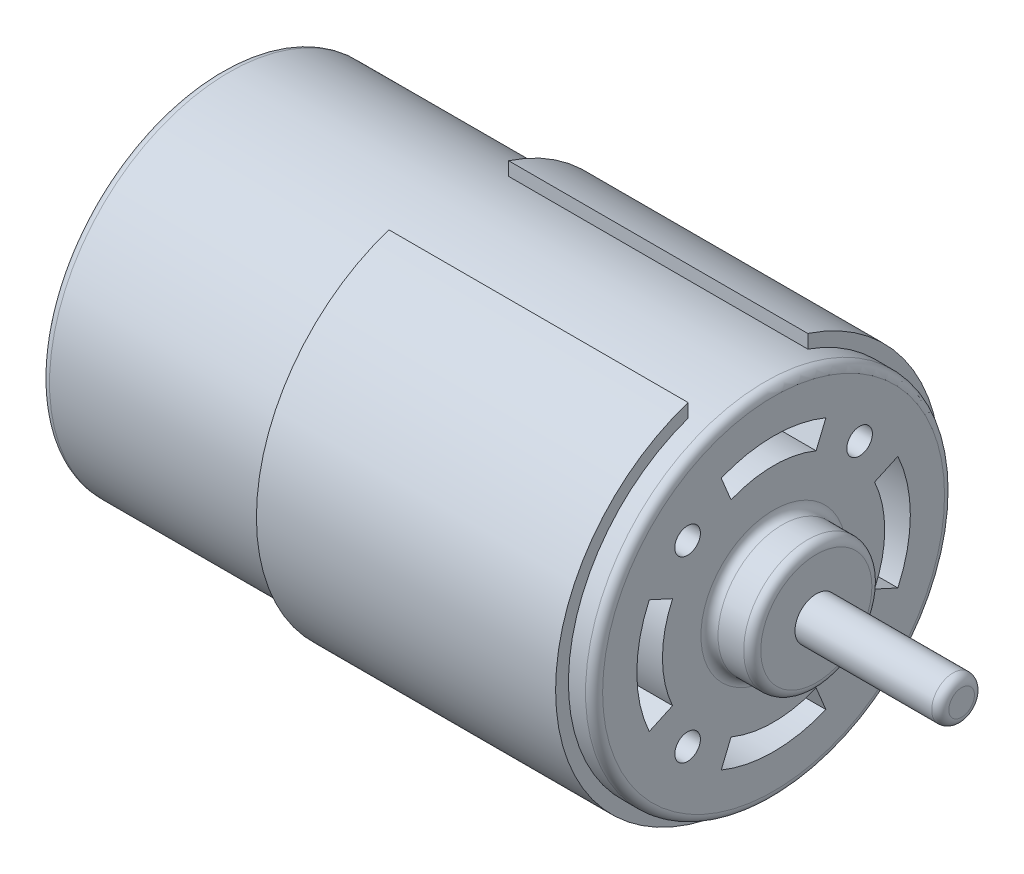
from build123d import *

# Parameters (mm, degrees)
SKETCH1_R               = 21
BOSS_EXTRUDE1_DEPTH     = 26.7
SKETCH2_R               = 22.5
BOSS_EXTRUDE2_DEPTH     = 35
SKETCH3_R               = 21
BOSS_EXTRUDE3_DEPTH     = 3
SKETCH4_R               = 7.5
BOSS_EXTRUDE4_DEPTH     = 5
SKETCH5_R               = 2.5
BOSS_EXTRUDE5_DEPTH     = 17
CUT_EXTRUDE1_REACH      = 105.824
CUT_EXTRUDE1_END_RADIUS = 21
SKETCH6_W               = 35
SKETCH6_H               = 14
FILLET1_R               = 1
SKETCH7_R               = 7.5
BOSS_EXTRUDE6_DEPTH     = 5
SKETCH8_R               = 2.5
BOSS_EXTRUDE7_DEPTH     = 5
CHAMFER1_SIZE           = 2
FILLET2_R               = 1
SKETCH9_R               = 1.5
CUT_EXTRUDE2_DEPTH      = 10


with BuildPart() as part:
    # Sketch1 → Boss-Extrude1 (new body)
    with BuildSketch(Plane(origin=(0, 0, 0), x_dir=(0, 0, -1), z_dir=(1, 0, 0))):
        with Locations(Location((0, 0, 0), (0, 0, 180))):
            Circle(SKETCH1_R)
    extrude(amount=BOSS_EXTRUDE1_DEPTH)

    # Sketch2 → Boss-Extrude2 (add)
    with BuildSketch(Plane(origin=(26.7, 0, 0), x_dir=(0, 0, -1), z_dir=(1, 0, 0))):
        Circle(SKETCH2_R)
    extrude(amount=BOSS_EXTRUDE2_DEPTH)

    # Sketch3 → Boss-Extrude3 (add)
    with BuildSketch(Plane(origin=(61.7, 0, 0), x_dir=(0, 0, -1), z_dir=(1, 0, 0))):
        with Locations(Location((0, 0, 0), (0, 0, 180))):
            Circle(SKETCH3_R)
    extrude(amount=BOSS_EXTRUDE3_DEPTH)

    # Sketch4 → Boss-Extrude4 (add)
    with BuildSketch(Plane(origin=(64.7, 0, 0), x_dir=(0, 0, -1), z_dir=(1, 0, 0))):
        Circle(SKETCH4_R)
    extrude(amount=BOSS_EXTRUDE4_DEPTH)

    # Sketch5 → Boss-Extrude5 (add)
    with BuildSketch(Plane(origin=(69.7, 0, 0), x_dir=(0, 0, -1), z_dir=(1, 0, 0))):
        Circle(SKETCH5_R)
    extrude(amount=BOSS_EXTRUDE5_DEPTH)

    # Cut-Extrude1: up to this cylinder (the profile starts outside it)
    cut_extrude1_end = Plane(origin=(44.2, 0, 0), z_dir=(-1, 0, 0)) * Cylinder(CUT_EXTRUDE1_END_RADIUS, 254.648, mode=Mode.PRIVATE)
    # Sketch6 → Cut-Extrude1 (cut, up to the surface)
    with BuildSketch(Plane(origin=(0, 30, 0), x_dir=(1, 0, 0), z_dir=(0, 1, 0)), mode=Mode.PRIVATE) as cut_extrude1_sk1:
        with Locations((44.2, 0)):
            Rectangle(SKETCH6_W, SKETCH6_H)
    cut_extrude1_tool1 = extrude(cut_extrude1_sk1.sketch, amount=-CUT_EXTRUDE1_REACH, mode=Mode.PRIVATE) - cut_extrude1_end
    add(cut_extrude1_tool1.solids().sort_by_distance((44.2, 30, 0))[0], mode=Mode.SUBTRACT)

    # Fillet1
    fillet1_edges = [part.edges().sort_by_distance(p)[0] for p in [
        (64.7, 0, -21),
        (64.7, 0, 7.5),
        (69.7, 0, 7.5),
        (0, 0, -21),
    ]]
    fillet(fillet1_edges, radius=FILLET1_R)

    # Sketch7 → Boss-Extrude6 (add)
    with BuildSketch(Plane.ZY):
        with Locations(Location((0, 0, 0), (0, 0, 180))):
            Circle(SKETCH7_R)
    extrude(amount=BOSS_EXTRUDE6_DEPTH)

    # Sketch8 → Boss-Extrude7 (add)
    with BuildSketch(Plane.ZY.offset(5)):
        with Locations(Location((0, 0, 0), (0, 0, 180))):
            Circle(SKETCH8_R)
    extrude(amount=BOSS_EXTRUDE7_DEPTH)

    # Chamfer1
    chamfer1_edges = [part.edges().sort_by_distance(p)[0] for p in [
        (-5, 0, 7.5),
    ]]
    chamfer(chamfer1_edges, length=CHAMFER1_SIZE)

    # Fillet2
    fillet2_edges = [part.edges().sort_by_distance(p)[0] for p in [
        (86.7, 0, 2.5),
        (0, 0, 7.5),
        (-10, 0, 2.5),
        (-3, 0, 7.5),
    ]]
    fillet(fillet2_edges, radius=FILLET2_R)

    # Sketch9 → Cut-Extrude2 (cut)
    with BuildSketch(Plane(origin=(64.7, 0, 0), x_dir=(0, 0, -1), z_dir=(1, 0, 0))):
        with Locations((-10.059860621, 10.442662701)):
            Circle(SKETCH9_R)
        with BuildLine():
            ThreePointArc((-4.974884621, 12.010433923), (-2.536174186, 12.750208645), (0, 13))
            ThreePointArc((0, 13), (2.536174186, 12.750208645), (4.974884621, 12.010433923))
            Line((4.974884621, 12.010433923), (5.548909769, 13.396253221))
            Line((5.548909769, 13.396253221), (6.122934918, 14.78207252))
            ThreePointArc((6.122934918, 14.78207252), (3.121445152, 15.692564486), (0, 16))
            ThreePointArc((0, 16), (-3.121445152, 15.692564486), (-6.122934918, 14.78207252))
            Line((-6.122934918, 14.78207252), (-5.548909769, 13.396253221))
            Line((-5.548909769, 13.396253221), (-4.974884621, 12.010433923))
        make_face()
        with Locations((10.059860621, 10.442662701)):
            Circle(SKETCH9_R)
        with BuildLine():
            ThreePointArc((11.816355895, 5.419753994), (12.70064224, 2.773749571), (13, 0))
            ThreePointArc((13, 0), (12.70064224, -2.773749571), (11.816355895, -5.419753994))
            Line((11.816355895, -5.419753994), (13.179781576, -6.045110224))
            Line((13.179781576, -6.045110224), (14.543207256, -6.670466454))
            ThreePointArc((14.543207256, -6.670466454), (15.631559681, -3.413845625), (16, 0))
            ThreePointArc((16, 0), (15.631559681, 3.413845625), (14.543207256, 6.670466454))
            Line((14.543207256, 6.670466454), (13.179781576, 6.045110224))
            Line((13.179781576, 6.045110224), (11.816355895, 5.419753994))
        make_face()
        with Locations((10.059860621, -10.442662701)):
            Circle(SKETCH9_R)
        with BuildLine():
            ThreePointArc((4.974884621, -12.010433923), (2.536174186, -12.750208645), (0, -13))
            ThreePointArc((0, -13), (-2.536174186, -12.750208645), (-4.974884621, -12.010433923))
            Line((-4.974884621, -12.010433923), (-5.548909769, -13.396253221))
            Line((-5.548909769, -13.396253221), (-6.122934918, -14.78207252))
            ThreePointArc((-6.122934918, -14.78207252), (-3.121445152, -15.692564486), (0, -16))
            ThreePointArc((0, -16), (3.121445152, -15.692564486), (6.122934918, -14.78207252))
            Line((6.122934918, -14.78207252), (5.548909769, -13.396253221))
            Line((5.548909769, -13.396253221), (4.974884621, -12.010433923))
        make_face()
        with Locations((-10.059860621, -10.442662701)):
            Circle(SKETCH9_R)
        with BuildLine():
            ThreePointArc((-11.816355895, -5.419753994), (-12.70064224, -2.773749571), (-13, 0))
            ThreePointArc((-13, 0), (-12.70064224, 2.773749571), (-11.816355895, 5.419753994))
            Line((-11.816355895, 5.419753994), (-13.179781576, 6.045110224))
            Line((-13.179781576, 6.045110224), (-14.543207256, 6.670466454))
            ThreePointArc((-14.543207256, 6.670466454), (-15.631559681, 3.413845625), (-16, 0))
            ThreePointArc((-16, 0), (-15.631559681, -3.413845625), (-14.543207256, -6.670466454))
            Line((-14.543207256, -6.670466454), (-13.179781576, -6.045110224))
            Line((-13.179781576, -6.045110224), (-11.816355895, -5.419753994))
        make_face()
    extrude(amount=-CUT_EXTRUDE2_DEPTH, mode=Mode.SUBTRACT)


solid = part.part
